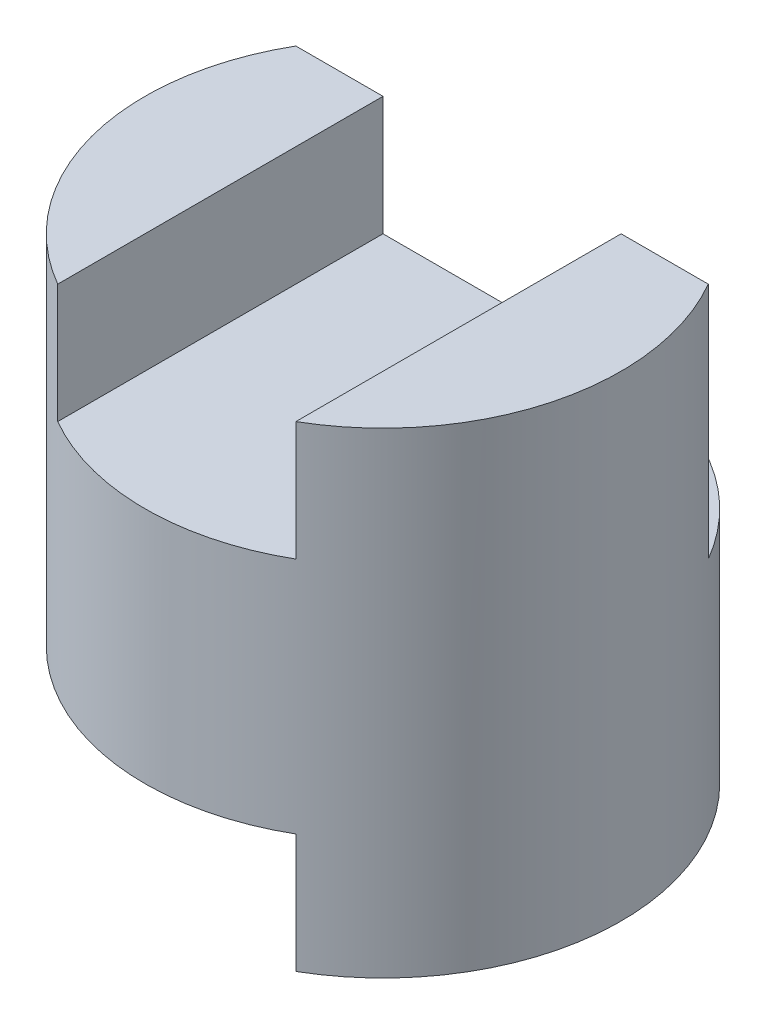
from build123d import *

# Parameters (mm, degrees)
SKETCH1_R               = 2
BOSS_EXTRUDE1_DEPTH     = 4
SKETCH2_W               = 2
SKETCH2_H               = 1
SKETCH2_W_2             = 3
CUT_EXTRUDE1_DEPTH      = 3
CUT_EXTRUDE1_DEPTH_BACK = 1
CUT_EXTRUDE2_DEPTH      = 2


with BuildPart() as part:
    # Sketch1 → Boss-Extrude1 (new body)
    with BuildSketch(Plane(origin=(0, 0, 0), x_dir=(1, 0, 0), z_dir=(0, 1, 0))):
        Circle(SKETCH1_R)
    extrude(amount=BOSS_EXTRUDE1_DEPTH)

    # Sketch2 → Cut-Extrude1 (cut, two sides)
    with BuildSketch(Plane.XY) as cut_extrude1_sk:
        with Locations((0, 3.5)):
            Rectangle(SKETCH2_W, SKETCH2_H)
        with Locations((-0.5, 0.5)):
            Rectangle(SKETCH2_W_2, SKETCH2_H)
    extrude(amount=CUT_EXTRUDE1_DEPTH, mode=Mode.SUBTRACT)
    extrude(cut_extrude1_sk.sketch, amount=-CUT_EXTRUDE1_DEPTH_BACK, mode=Mode.SUBTRACT)

    # Sketch3 → Cut-Extrude2 (cut)
    with BuildSketch(Plane(origin=(0, 4, 0), x_dir=(1, 0, 0), z_dir=(0, 1, 0))):
        with BuildLine():
            Line((-1.732050808, 1), (1.732050808, 1))
            ThreePointArc((1.732050808, 1), (0, 2), (-1.732050808, 1))
        make_face()
    extrude(amount=-CUT_EXTRUDE2_DEPTH, mode=Mode.SUBTRACT)


solid = part.part
